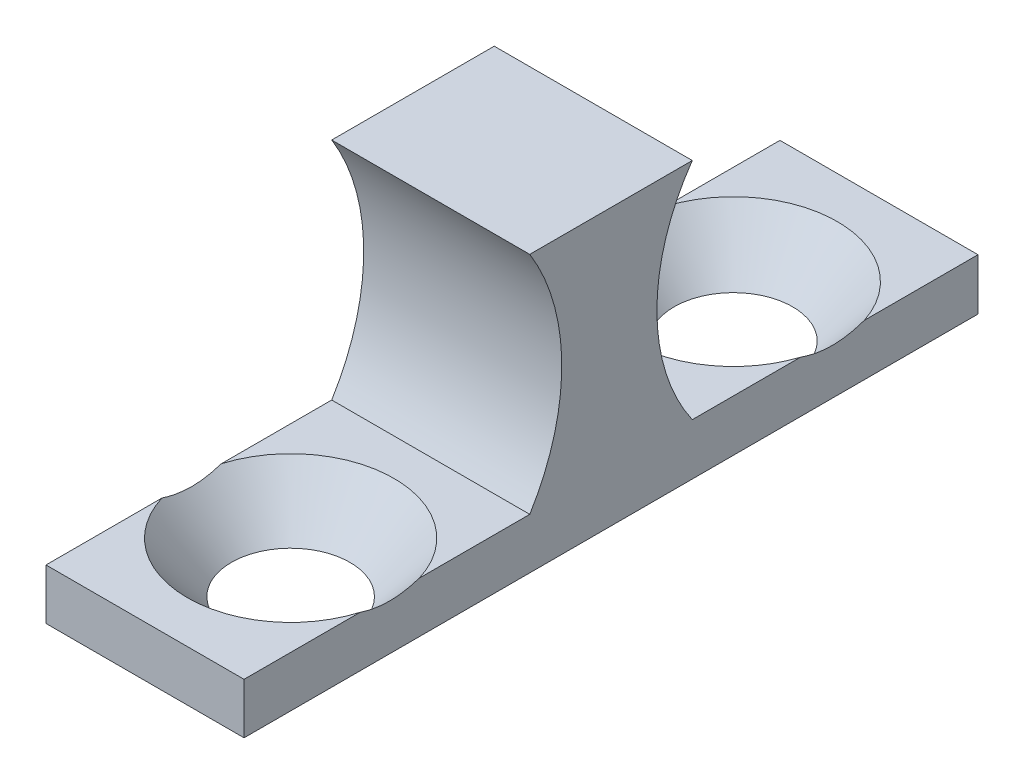
from build123d import *

# Parameters (mm, degrees)
BOSS_EXTRUDE2_DEPTH                           = 6.746875
CUT_EXTRUDE1_REACH                            = 8.747
CSK_FOR_6_FLAT_HEAD_MACHINE_SCREW1_AT_2_COUNT = 2
CSK_FOR_6_FLAT_HEAD_MACHINE_SCREW1_AT_2_PITCH = 15.08125


with BuildPart() as part:
    # Sketch2 → Boss-Extrude2 (new body)
    with BuildSketch(Plane(origin=(0, 0, 0), x_dir=(0, 0, -1), z_dir=(1, 0, 0))):
        Polygon((-2.049136217, 1.594614568), (-11.782098717, 1.594614568), (-11.782098717, -0.132585432), (13.221026283, -0.132585432), (13.221026283, 1.620014568), (3.488063783, 1.620014568), (3.488063783, 9.265414568), (-2.049136217, 9.265414568), align=None)
    extrude(amount=BOSS_EXTRUDE2_DEPTH)

    # Sketch9 → Cut-Extrude1 (cut, up to next)
    with BuildSketch(Plane(origin=(6.746875, 0, 0), x_dir=(0, 0, -1), z_dir=(1, 0, 0)), mode=Mode.PRIVATE) as cut_extrude1_sk1:
        with BuildLine():
            Line((-2.049136217, 9.265414568), (-2.049136217, 1.594614568))
            ThreePointArc((-2.049136217, 1.594614568), (-0.958515707, 5.430014568), (-2.049136217, 9.265414568))
        make_face()
    cut_extrude1_tool1 = extrude(cut_extrude1_sk1.sketch, amount=-CUT_EXTRUDE1_REACH, mode=Mode.PRIVATE) & part.part
    add(cut_extrude1_tool1.solids().sort_by_distance((6.746875, 5.430015, 1.609964))[0], mode=Mode.SUBTRACT)
    # Sketch9 → Cut-Extrude1 (cut, up to next)
    with BuildSketch(Plane(origin=(6.746875, 0, 0), x_dir=(0, 0, -1), z_dir=(1, 0, 0)), mode=Mode.PRIVATE) as cut_extrude1_sk2:
        with BuildLine():
            Line((3.488063783, 9.265414568), (3.488063783, 1.620014568))
            ThreePointArc((3.488063783, 1.620014568), (2.281768381, 5.442714568), (3.488063783, 9.265414568))
        make_face()
    cut_extrude1_tool2 = extrude(cut_extrude1_sk2.sketch, amount=-CUT_EXTRUDE1_REACH, mode=Mode.PRIVATE) & part.part
    add(cut_extrude1_tool2.solids().sort_by_distance((6.746875, 5.442715, -3.001592))[0], mode=Mode.SUBTRACT)

    # Sketch7 → CSK for #6 Flat Head Machine Screw1 (revolve, cut)
    with BuildSketch(Plane(origin=(3.374760147, 1.620014568, -8.260088783), x_dir=(0, 0, 1), z_dir=(1, 0, 0))):
        Polygon((0, 0), (0, 1.7526), (1.89865, 1.7526), (1.89865, 1.891953401), (3.5433, 0), align=None)
    csk_for_6_flat_head_machine_screw1 = revolve(axis=Axis((3.374760147, 7.970014568, -8.260088783), (0, -1, 0)), mode=Mode.SUBTRACT)

    # CSK for #6 Flat Head Machine Screw1 at 2: CSK for #6 Flat Head Machine Screw1 ×2
    with Locations(*[Vector(-8.7701e-05, 0, 0.999999996) * (i * CSK_FOR_6_FLAT_HEAD_MACHINE_SCREW1_AT_2_PITCH) for i in range(1, CSK_FOR_6_FLAT_HEAD_MACHINE_SCREW1_AT_2_COUNT)]):
        add(csk_for_6_flat_head_machine_screw1, mode=Mode.SUBTRACT)


solid = part.part
